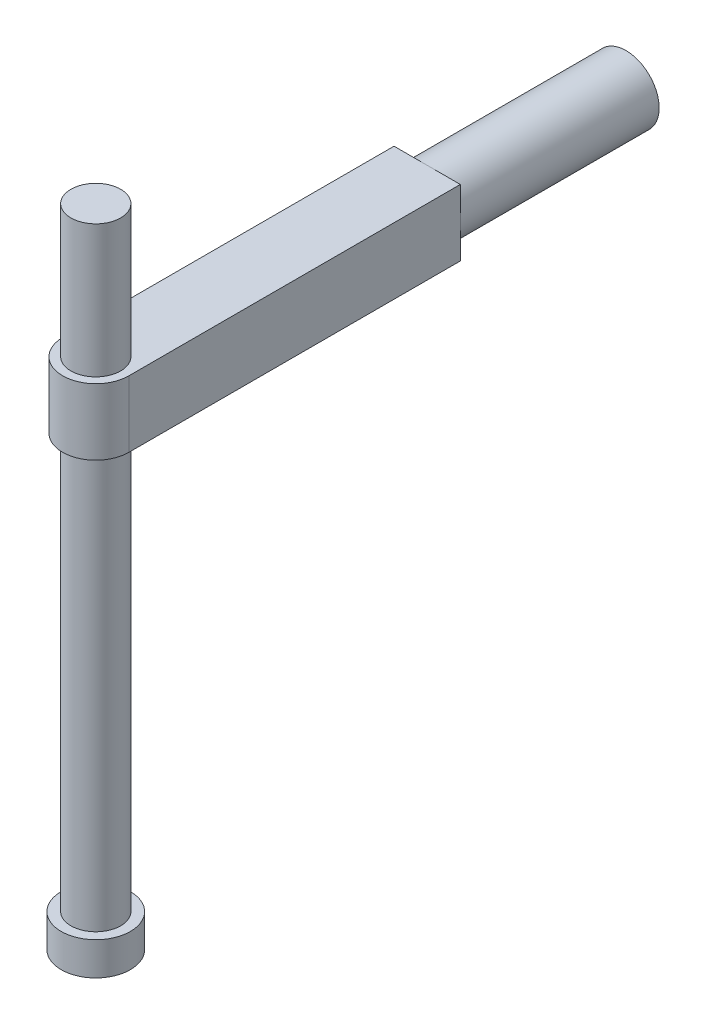
from build123d import *

# Parameters (mm, degrees)
BOSS_EXTRUDE1_DEPTH = 4
SKETCH2_R           = 1.5
BOSS_EXTRUDE2_DEPTH = 37
SKETCH3_R           = 2.086060033
BOSS_EXTRUDE3_DEPTH = 2
SKETCH4_W           = 5
SKETCH4_H           = 3.576334768
CUT_EXTRUDE1_DEPTH  = 32
SKETCH5_R           = 2
BOSS_EXTRUDE4_DEPTH = 12


with BuildPart() as part:
    # Sketch1 → Boss-Extrude1 (new body)
    with BuildSketch(Plane(origin=(0, 0, 0), x_dir=(1, 0, 0), z_dir=(0, 1, 0))):
        with BuildLine():
            Line((-2, 0), (-2, 20))
            ThreePointArc((-2, 20), (0, 22), (2, 20))
            Line((2, 20), (2, 0))
            ThreePointArc((2, 0), (0, -2), (-2, 0))
        make_face()
    extrude(amount=BOSS_EXTRUDE1_DEPTH)

    # Sketch2 → Boss-Extrude2 (add)
    with BuildSketch(Plane(origin=(0, 12, 0), x_dir=(1, 0, 0), z_dir=(0, 1, 0))):
        Circle(SKETCH2_R)
    extrude(amount=-BOSS_EXTRUDE2_DEPTH)

    # Sketch3 → Boss-Extrude3 (add)
    with BuildSketch(Plane.XZ.offset(25)):
        Circle(SKETCH3_R)
    extrude(amount=BOSS_EXTRUDE3_DEPTH)

    # Sketch4 → Cut-Extrude1 (cut, through all)
    with BuildSketch(Plane(origin=(0, 4, 0), x_dir=(1, 0, 0), z_dir=(0, 1, 0))):
        with Locations((0.5, 21.788167384)):
            Rectangle(SKETCH4_W, SKETCH4_H)
    extrude(amount=-CUT_EXTRUDE1_DEPTH, mode=Mode.SUBTRACT)

    # Sketch5 → Boss-Extrude4 (add)
    with BuildSketch(Plane(origin=(0, 0, -20), x_dir=(-1, 0, 0), z_dir=(0, 0, -1))):
        with Locations((0, 2)):
            Circle(SKETCH5_R)
    extrude(amount=BOSS_EXTRUDE4_DEPTH)


solid = part.part
